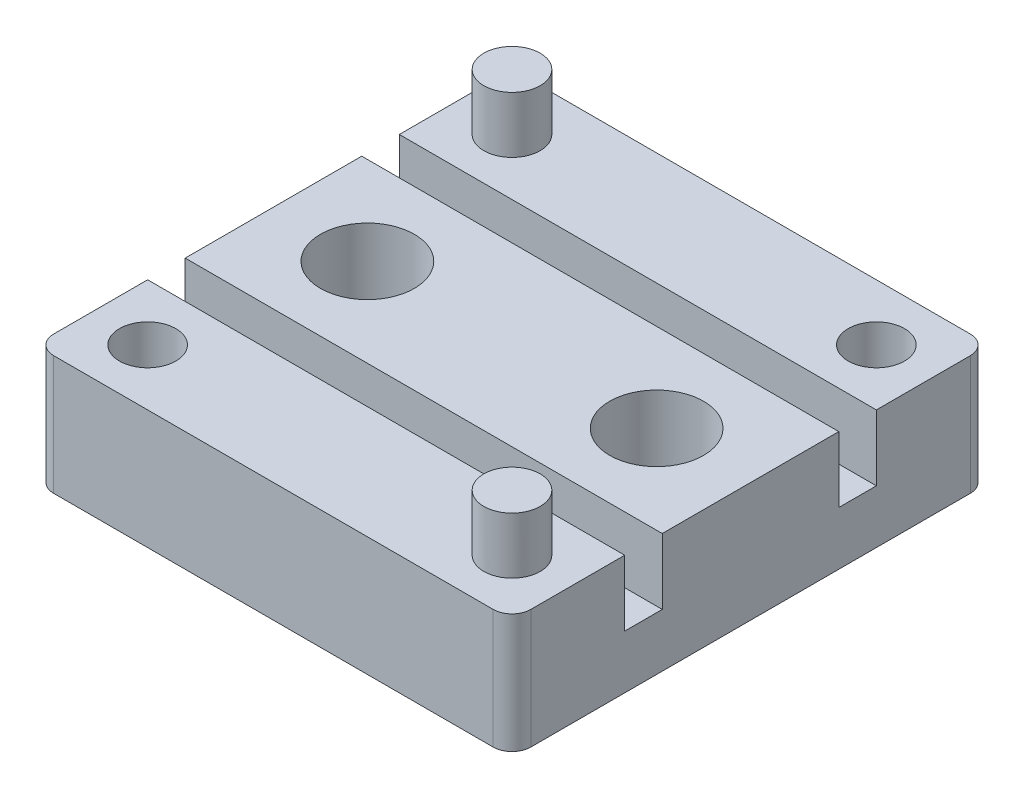
from build123d import *

# Parameters (mm, degrees)
SKETCH1_W            = 12.7
SKETCH1_H            = 12.7
SKETCH1_R            = 1.25
BOSS_EXTRUDE1_DEPTH  = 3.175
SKETCH2_R            = 0.75
BOSS_EXTRUDE2_DEPTH  = 1.5
SKETCH3_R            = 0.75
CUT_EXTRUDE1_DEPTH   = 1.5
SKETCH4_W            = 12.7
SKETCH4_H            = 1
CUT_EXTRUDE2_DEPTH   = 1.75
SKETCH5_W            = 7
SKETCH5_H            = 1
CUT_EXTRUDE3_DEPTH   = 0.75
FILLET1_R            = 0.25
FILLET2_R            = 0.5
FILLET1_OF_MIRROR3_R = 0.25


with BuildPart() as part:
    # Sketch1 → Boss-Extrude1 (new body)
    with BuildSketch(Plane(origin=(0, 0, 0), x_dir=(1, 0, 0), z_dir=(0, 1, 0))):
        with Locations((-6.35, 6.35)):
            Rectangle(SKETCH1_W, SKETCH1_H)
        with Locations((-2.5, 6.35)):
            Circle(SKETCH1_R, mode=Mode.SUBTRACT)
        with Locations((-10.2, 6.35)):
            Circle(SKETCH1_R, mode=Mode.SUBTRACT)
    extrude(amount=BOSS_EXTRUDE1_DEPTH)

    # Sketch2 → Boss-Extrude2 (add)
    with BuildSketch(Plane(origin=(0, 3.175, 0), x_dir=(1, 0, 0), z_dir=(0, 1, 0))):
        with Locations((-11.2, 11.2)):
            Circle(SKETCH2_R)
    boss_extrude2 = extrude(amount=BOSS_EXTRUDE2_DEPTH)

    # Sketch3 → Cut-Extrude1 (cut)
    with BuildSketch(Plane(origin=(0, 3.175, 0), x_dir=(1, 0, 0), z_dir=(0, 1, 0))):
        with Locations((-1.5, 11.2)):
            Circle(SKETCH3_R)
    cut_extrude1 = extrude(amount=-CUT_EXTRUDE1_DEPTH, mode=Mode.SUBTRACT)

    # Mirror1: Boss-Extrude2 across plane
    add(boss_extrude2.mirror(Plane(origin=(-6.35, 0, -6.35), x_dir=(-0.707106781, 0, 0.707106781), z_dir=(-0.707106781, 0, -0.707106781))))

    # Mirror2: Cut-Extrude1 across plane
    add(cut_extrude1.mirror(Plane(origin=(0, 0, 0), x_dir=(0.707106781, 0, 0.707106781), z_dir=(-0.707106781, 0, 0.707106781))), mode=Mode.SUBTRACT)

    # Sketch4 → Cut-Extrude2 (cut)
    with BuildSketch(Plane(origin=(0, 3.175, 0), x_dir=(1, 0, 0), z_dir=(0, 1, 0))):
        with Locations((-6.35, 9.2)):
            Rectangle(SKETCH4_W, SKETCH4_H)
    cut_extrude2 = extrude(amount=-CUT_EXTRUDE2_DEPTH, mode=Mode.SUBTRACT)

    # Sketch5 → Cut-Extrude3 (cut)
    with BuildSketch(Plane(origin=(0, 1.425, 0), x_dir=(1, 0, 0), z_dir=(0, 1, 0))):
        with Locations((-6.35, 9.2)):
            Rectangle(SKETCH5_W, SKETCH5_H)
    cut_extrude3 = extrude(amount=-CUT_EXTRUDE3_DEPTH, mode=Mode.SUBTRACT)

    # Fillet1
    fillet1_edges = [part.edges().sort_by_distance(p)[0] for p in [
        (-9.85, 0.675, -9.2),
        (-2.85, 0.675, -9.2),
        (-9.85, 1.425, -9.2),
        (-2.85, 1.425, -9.2),
    ]]
    fillet(fillet1_edges, radius=FILLET1_R)

    # Fillet2
    fillet2_edges = [part.edges().sort_by_distance(p)[0] for p in [
        (0, 1.5875, 0),
        (-12.7, 1.5875, 0),
        (-12.7, 1.5875, -12.7),
        (0, 1.5875, -12.7),
    ]]
    fillet(fillet2_edges, radius=FILLET2_R)

    # Mirror3: Cut-Extrude2, Cut-Extrude3 across plane
    add(cut_extrude2.mirror(Plane(origin=(0, 0, -6.35), x_dir=(1, 0, 0), z_dir=(0, 0, -1))), mode=Mode.SUBTRACT)
    add(cut_extrude3.mirror(Plane(origin=(0, 0, -6.35), x_dir=(1, 0, 0), z_dir=(0, 0, -1))), mode=Mode.SUBTRACT)

    # Fillet1 of Mirror3
    fillet1_of_mirror3_edges = [part.edges().sort_by_distance(p)[0] for p in [
        (-9.85, 0.675, -3.5),
        (-2.85, 0.675, -3.5),
        (-9.85, 1.425, -3.5),
        (-2.85, 1.425, -3.5),
    ]]
    fillet(fillet1_of_mirror3_edges, radius=FILLET1_OF_MIRROR3_R)


solid = part.part
